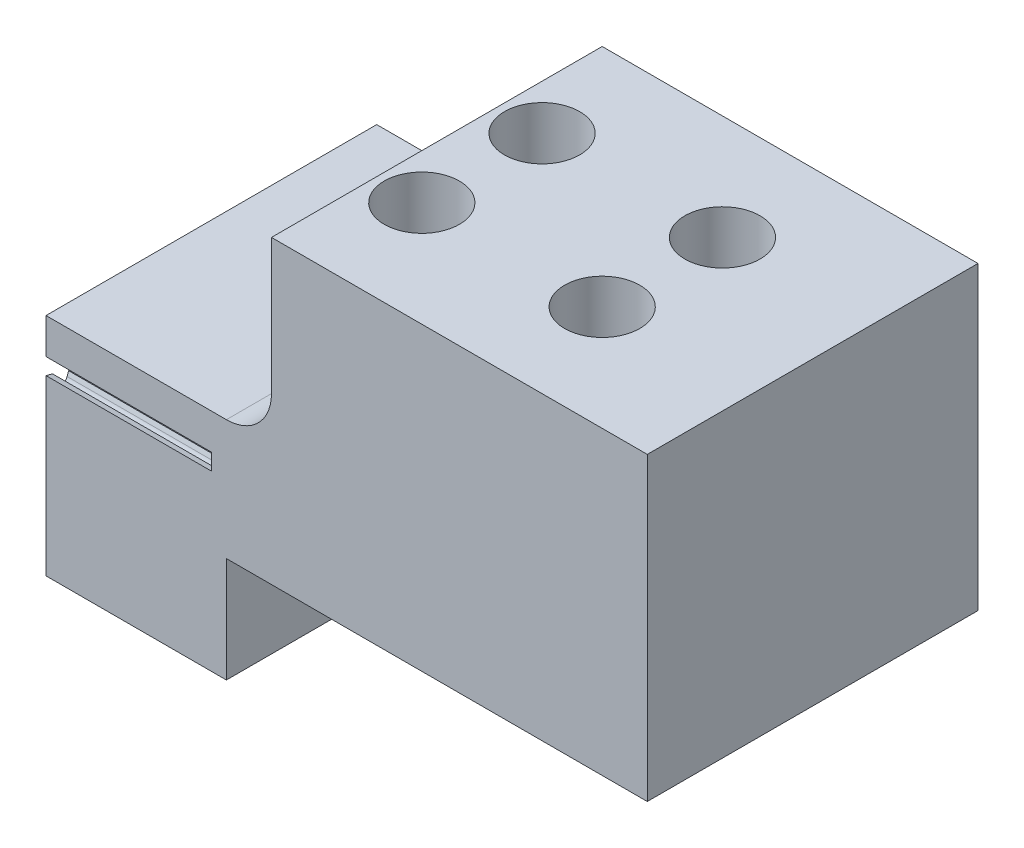
from build123d import *

# Parameters (mm, degrees)
SKETCH_1_W                   = 20
SKETCH_1_H                   = 40
EXTRUDE_1_DEPTH              = 30
CUT_EXTRUDE_1_DEPTH          = 11
SKETCH_13_W                  = 20
SKETCH_13_H                  = 30
CUT_EXTRUDE_5_DEPTH          = 10
SKETCH_14_W                  = 30
SKETCH_14_H                  = 30
EXTRUDE_5_DEPTH              = 20
HOLE_WIZARD_M2_1_D           = 2.4
HOLE_WIZARD_M2_1_CSINK_D     = 2.45
HOLE_WIZARD_M2_1_CSINK_ANGLE = 90
SKETCH_19_R                  = 2.5
CUT_EXTRUDE_6_DEPTH          = 12
SKETCH_20_W                  = 4
SKETCH_20_H                  = 30
CUT_EXTRUDE_7_DEPTH          = 49
SKETCH_22_W                  = 28
SKETCH_22_H                  = 22
CUT_EXTRUDE_8_DEPTH          = 10
SKETCH_23_W                  = 12
SKETCH_23_H                  = 3
CUT_EXTRUDE_9_DEPTH          = 23
SKETCH_24_W                  = 3.41182091
SKETCH_24_H                  = 4.86270688
CUT_EXTRUDE_10_DEPTH         = 11
SKETCH_25_W                  = 15
SKETCH_25_H                  = 22
CUT_EXTRUDE_11_DEPTH         = 12
FILLET_1_R                   = 3


with BuildPart() as part:
    # 草图1 → 凸台-拉伸1 (new body)
    with BuildSketch(Plane.XY):
        with Locations((10, 20)):
            Rectangle(SKETCH_1_W, SKETCH_1_H)
    extrude(amount=EXTRUDE_1_DEPTH)

    # 草图3 → 切除-拉伸1 (cut)
    with BuildSketch(Plane.ZY):
        with BuildLine():
            Line((2.42076783, 14.560970744), (2.46639251, 14.857401496))
            ThreePointArc((2.46639251, 14.857401496), (2.019622743, 14.921117547), (1.571223609, 14.972119278))
            Line((1.571223609, 14.972119278), (1.540625063, 14.673762896))
            ThreePointArc((1.540625063, 14.673762896), (0.958467816, 14.180991438), (0.443670306, 14.743765188))
            Line((0.443670306, 14.743765188), (0.451244703, 15.043586442))
            ThreePointArc((0.451244703, 15.043586442), (0.225645108, 15.048393221), (0, 15.049995588))
            Line((0, 15.049995588), (0, 16.111542732))
            ThreePointArc((0, 16.111542732), (8.761075107, 13.671748208), (15, 7.054736002))
            ThreePointArc((15, 7.054736002), (21.238924893, 13.671748208), (30, 16.111542732))
            Line((30, 16.111542732), (30, 15.049995588))
            ThreePointArc((30, 15.049995588), (29.774354892, 15.048393221), (29.548755297, 15.043586442))
            Line((29.548755297, 15.043586442), (29.556329694, 14.743765188))
            ThreePointArc((29.556329694, 14.743765188), (29.041532184, 14.180991438), (28.459374937, 14.673762896))
            Line((28.459374937, 14.673762896), (28.428776391, 14.972119278))
            ThreePointArc((28.428776391, 14.972119278), (27.980377257, 14.921117547), (27.53360749, 14.857401496))
            Line((27.53360749, 14.857401496), (27.57923217, 14.560970744))
            ThreePointArc((27.57923217, 14.560970744), (27.140146166, 13.937324811), (26.500073756, 14.352099545))
            Line((26.500073756, 14.352099545), (26.431798568, 14.644146289))
            ThreePointArc((26.431798568, 14.644146289), (25.993519676, 14.536561099), (25.558473085, 14.416571838))
            Line((25.558473085, 14.416571838), (25.641407746, 14.128345115))
            ThreePointArc((25.641407746, 14.128345115), (25.285156719, 13.453944659), (24.597553302, 13.78399361))
            Line((24.597553302, 13.78399361), (24.492709128, 14.064992722))
            ThreePointArc((24.492709128, 14.064992722), (24.071660856, 13.902569472), (23.655395377, 13.728253635))
            Line((23.655395377, 13.728253635), (23.774294539, 13.45290696))
            ThreePointArc((23.774294539, 13.45290696), (23.506658094, 12.738693055), (22.78267894, 12.978661705))
            Line((22.78267894, 12.978661705), (22.642966709, 13.244054422))
            ThreePointArc((22.642966709, 13.244054422), (22.245979893, 13.029428171), (21.855248772, 12.803613755))
            Line((21.855248772, 12.803613755), (22.008183484, 12.545614189))
            ThreePointArc((22.008183484, 12.545614189), (21.833503597, 11.803173817), (21.084894113, 11.949169057))
            Line((21.084894113, 11.949169057), (20.912580434, 12.194649806))
            ThreePointArc((20.912580434, 12.194649806), (20.546095554, 11.931302521), (20.187237779, 11.657653005))
            Line((20.187237779, 11.657653005), (20.37172692, 11.421186181))
            ThreePointArc((20.37172692, 11.421186181), (20.292837493, 10.662564255), (19.531742677, 10.712217544))
            Line((19.531742677, 10.712217544), (19.329623065, 10.93380379))
            ThreePointArc((19.329623065, 10.93380379), (18.999585753, 10.626007863), (18.678423221, 10.308962775))
            Line((18.678423221, 10.308962775), (18.891473749, 10.097864989))
            ThreePointArc((18.891473749, 10.097864989), (18.909654637, 9.335368941), (18.148422038, 9.287874734))
            Line((18.148422038, 9.287874734), (17.919775562, 9.481971593))
            ThreePointArc((17.919775562, 9.481971593), (17.631540148, 9.134720523), (17.35328321, 8.779423413))
            Line((17.35328321, 8.779423413), (17.591438718, 8.597119392))
            ThreePointArc((17.591438718, 8.597119392), (17.706394965, 7.843119504), (16.957374371, 7.699248319))
            Line((16.957374371, 7.699248319), (16.705910455, 7.86270688))
            ThreePointArc((16.705910455, 7.86270688), (16.4641531, 7.481634261), (16.233316031, 7.093849259))
            Line((16.233316031, 7.093849259), (16.492712825, 6.943296595))
            ThreePointArc((16.492712825, 6.943296595), (16.68180457, 6.174165972), (15.906222101, 6.013575078))
            Line((15.906222101, 6.013575078), (15.906222101, 3.404183419))
            Line((15.906222101, 3.404183419), (14.093777899, 3.404183419))
            Line((14.093777899, 3.404183419), (14.093777899, 6.013575078))
            ThreePointArc((14.093777899, 6.013575078), (13.31819543, 6.174165972), (13.507287175, 6.943296595))
            Line((13.507287175, 6.943296595), (13.766683969, 7.093849259))
            ThreePointArc((13.766683969, 7.093849259), (13.5358469, 7.481634261), (13.294089545, 7.86270688))
            Line((13.294089545, 7.86270688), (13.042625629, 7.699248319))
            ThreePointArc((13.042625629, 7.699248319), (12.293605035, 7.843119504), (12.408561282, 8.597119392))
            Line((12.408561282, 8.597119392), (12.64671679, 8.779423413))
            ThreePointArc((12.64671679, 8.779423413), (12.368459852, 9.134720523), (12.080224438, 9.481971593))
            Line((12.080224438, 9.481971593), (11.851577962, 9.287874734))
            ThreePointArc((11.851577962, 9.287874734), (11.090345363, 9.335368941), (11.108526251, 10.097864989))
            Line((11.108526251, 10.097864989), (11.321576779, 10.308962775))
            ThreePointArc((11.321576779, 10.308962775), (11.000414247, 10.626007863), (10.670376935, 10.93380379))
            Line((10.670376935, 10.93380379), (10.468257323, 10.712217544))
            ThreePointArc((10.468257323, 10.712217544), (9.707162507, 10.662564255), (9.62827308, 11.421186181))
            Line((9.62827308, 11.421186181), (9.812762221, 11.657653005))
            ThreePointArc((9.812762221, 11.657653005), (9.453904446, 11.931302521), (9.087419566, 12.194649806))
            Line((9.087419566, 12.194649806), (8.915105887, 11.949169057))
            ThreePointArc((8.915105887, 11.949169057), (8.166496403, 11.803173817), (7.991816516, 12.545614189))
            Line((7.991816516, 12.545614189), (8.144751228, 12.803613755))
            ThreePointArc((8.144751228, 12.803613755), (7.754020107, 13.029428171), (7.357033291, 13.244054422))
            Line((7.357033291, 13.244054422), (7.21732106, 12.978661705))
            ThreePointArc((7.21732106, 12.978661705), (6.493341906, 12.738693055), (6.225705461, 13.45290696))
            Line((6.225705461, 13.45290696), (6.344604623, 13.728253635))
            ThreePointArc((6.344604623, 13.728253635), (5.928339144, 13.902569472), (5.507290872, 14.064992722))
            Line((5.507290872, 14.064992722), (5.402446698, 13.78399361))
            ThreePointArc((5.402446698, 13.78399361), (4.714843281, 13.453944659), (4.358592254, 14.128345115))
            Line((4.358592254, 14.128345115), (4.441526915, 14.416571838))
            ThreePointArc((4.441526915, 14.416571838), (4.006480324, 14.536561099), (3.568201432, 14.644146289))
            Line((3.568201432, 14.644146289), (3.499926244, 14.352099545))
            ThreePointArc((3.499926244, 14.352099545), (2.859853834, 13.937324811), (2.42076783, 14.560970744))
        make_face()
    extrude(amount=-CUT_EXTRUDE_1_DEPTH, mode=Mode.SUBTRACT)

    # 草图13 → 切除-拉伸5 (cut)
    with BuildSketch(Plane(origin=(0, 40, 0), x_dir=(1, 0, 0), z_dir=(0, 1, 0))):
        with Locations((10, -15)):
            Rectangle(SKETCH_13_W, SKETCH_13_H)
    extrude(amount=-CUT_EXTRUDE_5_DEPTH, mode=Mode.SUBTRACT)

    # 草图14 → 凸台-拉伸5 (add)
    with BuildSketch(Plane(origin=(20, 0, 0), x_dir=(0, 0, -1), z_dir=(1, 0, 0))):
        with Locations((-15, 15)):
            Rectangle(SKETCH_14_W, SKETCH_14_H)
    extrude(amount=EXTRUDE_5_DEPTH)

    # M2 间隙孔1 (through all)
    with Locations(Plane(origin=(0, 30, 0), x_dir=(1, 0, 0), z_dir=(0, 1, 0))):
        with Locations((18, -11), (30, -11), (18, -19), (30, -19)):
            CounterSinkHole(HOLE_WIZARD_M2_1_D / 2, HOLE_WIZARD_M2_1_CSINK_D / 2, counter_sink_angle=HOLE_WIZARD_M2_1_CSINK_ANGLE)

    # 草图19 → 切除-拉伸6 (cut)
    with BuildSketch(Plane(origin=(0, 30, 0), x_dir=(1, 0, 0), z_dir=(0, 1, 0))):
        with Locations((18, -11)):
            Circle(SKETCH_19_R)
        with Locations((30, -11)):
            Circle(SKETCH_19_R)
        with Locations((30, -19)):
            Circle(SKETCH_19_R)
        with Locations((18, -19)):
            Circle(SKETCH_19_R)
    extrude(amount=-CUT_EXTRUDE_6_DEPTH, mode=Mode.SUBTRACT)

    # 草图20 → 切除-拉伸7 (cut)
    with BuildSketch(Plane(origin=(40, 0, 0), x_dir=(0, 0, -1), z_dir=(1, 0, 0))):
        with Locations((-28, 15)):
            Rectangle(SKETCH_20_W, SKETCH_20_H)
        with Locations((-2, 15)):
            Rectangle(SKETCH_20_W, SKETCH_20_H)
    extrude(amount=-CUT_EXTRUDE_7_DEPTH, mode=Mode.SUBTRACT)

    # 草图22 → 切除-拉伸8 (cut)
    with BuildSketch(Plane.XZ):
        with Locations((26, 15)):
            Rectangle(SKETCH_22_W, SKETCH_22_H)
    extrude(amount=-CUT_EXTRUDE_8_DEPTH, mode=Mode.SUBTRACT)

    # 草图23 → 切除-拉伸9 (cut, through all)
    with BuildSketch(Plane.XY.offset(26)):
        with Locations((6, 1.5)):
            Rectangle(SKETCH_23_W, SKETCH_23_H)
    extrude(amount=-CUT_EXTRUDE_9_DEPTH, mode=Mode.SUBTRACT)

    # 草图24 → 切除-拉伸10 (cut)
    with BuildSketch(Plane.ZY):
        with Locations((15, 5.43135344)):
            Rectangle(SKETCH_24_W, SKETCH_24_H)
    extrude(amount=-CUT_EXTRUDE_10_DEPTH, mode=Mode.SUBTRACT)

    # 草图25 → 切除-拉伸11 (cut)
    with BuildSketch(Plane(origin=(0, 30, 0), x_dir=(1, 0, 0), z_dir=(0, 1, 0))):
        with Locations((7.5, -15)):
            Rectangle(SKETCH_25_W, SKETCH_25_H)
    extrude(amount=-CUT_EXTRUDE_11_DEPTH, mode=Mode.SUBTRACT)

    # 圆角1
    fillet_1_edges = [part.edges().sort_by_distance(p)[0] for p in [
        (15, 18, 15),
    ]]
    fillet(fillet_1_edges, radius=FILLET_1_R)


solid = part.part
